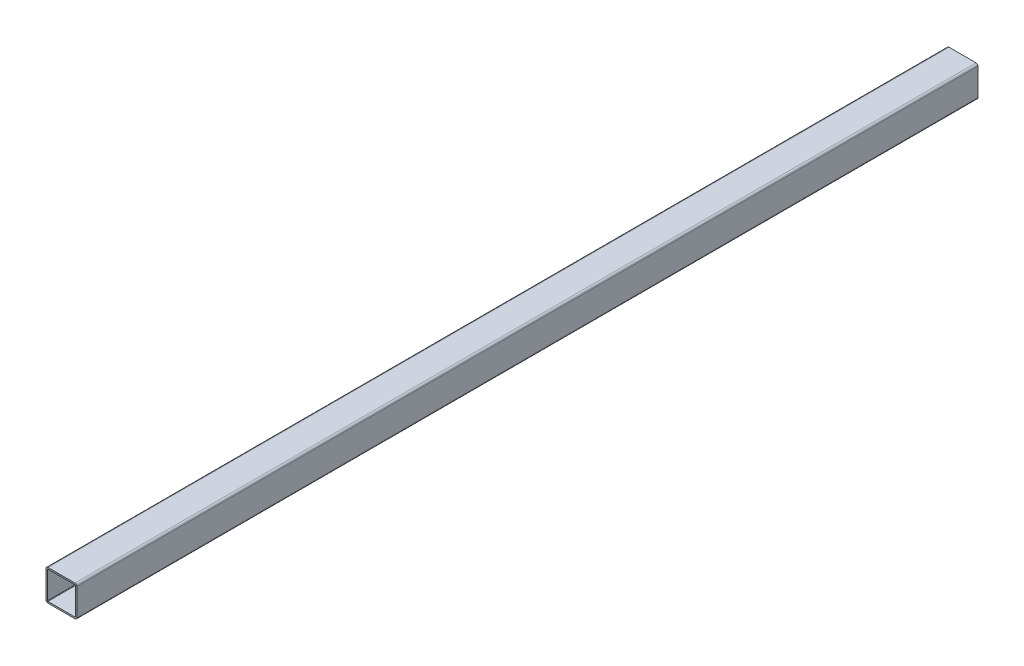
from build123d import *

# Parameters (mm, degrees)
BOSS_EXTRUDE1_DEPTH      = 466
BOSS_EXTRUDE1_DEPTH_BACK = 466


with BuildPart() as part:
    # Sketch1 → Boss-Extrude1 (new, two sides: drawn at the far end of the back side and taken through both)
    with BuildSketch(Plane.XY.offset(-BOSS_EXTRUDE1_DEPTH_BACK)):
        with BuildLine():
            Line((-14, -16), (14, -16))
            ThreePointArc((14, -16), (15.414213562, -15.414213562), (16, -14))
            Line((16, -14), (16, 14))
            ThreePointArc((16, 14), (15.414213562, 15.414213562), (14, 16))
            Line((14, 16), (-14, 16))
            ThreePointArc((-14, 16), (-15.414213562, 15.414213562), (-16, 14))
            Line((-16, 14), (-16, -14))
            ThreePointArc((-16, -14), (-15.414213562, -15.414213562), (-14, -16))
        make_face()
        with BuildLine():
            Line((-14, 14.48), (14, 14.48))
            ThreePointArc((14, 14.48), (14.339411255, 14.339411255), (14.48, 14))
            Line((14.48, 14), (14.48, -14))
            ThreePointArc((14.48, -14), (14.339411255, -14.339411255), (14, -14.48))
            Line((14, -14.48), (-14, -14.48))
            ThreePointArc((-14, -14.48), (-14.339411255, -14.339411255), (-14.48, -14))
            Line((-14.48, -14), (-14.48, 14))
            ThreePointArc((-14.48, 14), (-14.339411255, 14.339411255), (-14, 14.48))
        make_face(mode=Mode.SUBTRACT)
    extrude(amount=BOSS_EXTRUDE1_DEPTH + BOSS_EXTRUDE1_DEPTH_BACK)


solid = part.part
